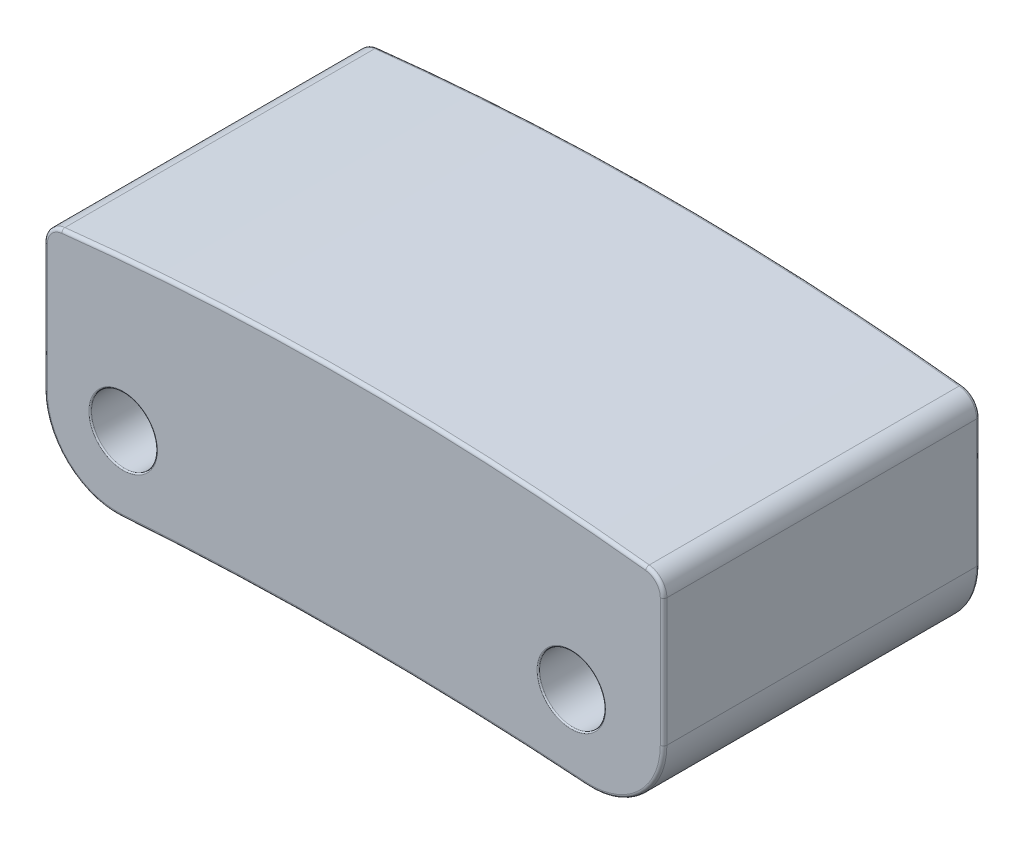
from build123d import *

# Parameters (mm, degrees)
SKETCH1_W               = 9.4
SKETCH1_H               = 3.7
BOSS_EXTRUDE1_DEPTH     = 2.4
CUT_EXTRUDE1_DEPTH      = 4.8
FILLET1_R               = 1.1
FILLET2_R               = 0.3
FILLET3_R               = 0.05
CUT_EXTRUDE2_START      = 1
SKETCH3_R               = 0.5
CUT_EXTRUDE2_DEPTH      = 4.8
FILLET4_R               = 0.02
CUT_EXTRUDE3_REACH      = 17.585
CUT_EXTRUDE3_END_RADIUS = 50.4
CUT_EXTRUDE3_START      = -10
SKETCH4_R               = 0.4
FILLET5_R               = 0.05


with BuildPart() as part:
    # Sketch1 → Boss-Extrude1 (new, symmetric)
    with BuildSketch(Plane.XY):
        Rectangle(SKETCH1_W, SKETCH1_H)
    extrude(amount=BOSS_EXTRUDE1_DEPTH, both=True)

    # Sketch2 → Cut-Extrude1 (cut)
    with BuildSketch(Plane.XY.offset(2.4)):
        with BuildLine():
            Line((-4.7, 1.55), (-7.120690005, 4.011417256))
            Line((-7.120690005, 4.011417256), (5.535860742, 3.886722174))
            Line((5.535860742, 3.886722174), (4.7, 1.55))
            ThreePointArc((4.7, 1.55), (0, 1.827084699), (-4.7, 1.55))
        make_face()
        with BuildLine():
            Line((4.7, -1.85), (0.350623614, -3.782025322))
            Line((0.350623614, -3.782025322), (-4.7, -1.85))
            ThreePointArc((-4.7, -1.85), (0, -1.628609864), (4.7, -1.85))
        make_face()
    extrude(amount=-CUT_EXTRUDE1_DEPTH, mode=Mode.SUBTRACT)

    # Fillet1
    fillet1_edges = [part.edges().sort_by_distance(p)[0] for p in [
        (4.7, -1.85, 0),
        (-4.7, -1.85, 0),
    ]]
    fillet(fillet1_edges, radius=FILLET1_R)

    # Fillet2
    fillet2_edges = [part.edges().sort_by_distance(p)[0] for p in [
        (4.7, 1.55, 0),
        (-4.7, 1.55, 0),
    ]]
    fillet(fillet2_edges, radius=FILLET2_R)

    # Fillet3
    fillet3_edges = [part.edges().sort_by_distance(p)[0] for p in [
        (4.7, 0.3134624, -2.4),
        (4.7, 0.3134624, 2.4),
        (0, -1.628609864, -2.4),
        (-4.349918456, -1.460327621, -2.4),
        (4.349918456, -1.460327621, -2.4),
        (0, -1.628609864, 2.4),
        (-4.349918456, -1.460327621, 2.4),
        (4.349918456, -1.460327621, 2.4),
        (0, 1.827084699, 2.4),
        (-4.7, 0.3134624, 2.4),
        (-4.623578634, 1.482534062, 2.4),
        (4.623578634, 1.482534062, 2.4),
        (0, 1.827084699, -2.4),
        (-4.7, 0.3134624, -2.4),
        (-4.623578634, 1.482534062, -2.4),
        (4.623578634, 1.482534062, -2.4),
    ]]
    fillet(fillet3_edges, radius=FILLET3_R)

    # Sketch3 → Cut-Extrude2 (cut)
    with BuildSketch(Plane.XY.offset(2.4).offset(CUT_EXTRUDE2_START)):
        with Locations((3.3, -0.6)):
            Circle(SKETCH3_R)
        with Locations((-3.5, -0.6)):
            Circle(SKETCH3_R)
    extrude(amount=-CUT_EXTRUDE2_DEPTH, mode=Mode.SUBTRACT)

    # Fillet4
    fillet4_edges = [part.edges().sort_by_distance(p)[0] for p in [
        (2.8, -0.6, 2.4),
        (-4, -0.6, 2.4),
    ]]
    fillet(fillet4_edges, radius=FILLET4_R)

    # Cut-Extrude3: up to this cylinder (the profile starts inside it)
    cut_extrude3_end = Plane(origin=(0, -51.628609864, 0.9), z_dir=(0, 0, 1)) * Cylinder(CUT_EXTRUDE3_END_RADIUS, 136.97, mode=Mode.PRIVATE)
    # Sketch4 → Cut-Extrude3 (cut, up to the surface)
    with BuildSketch(Plane(origin=(0, 0, 0), x_dir=(1, 0, 0), z_dir=(0, 1, 0)).offset(CUT_EXTRUDE3_START), mode=Mode.PRIVATE) as cut_extrude3_sk1:
        with Locations(Location((-0.05, -0.9, 0), (0, 0, 90))):
            Circle(SKETCH4_R)
    cut_extrude3_tool1 = extrude(cut_extrude3_sk1.sketch, amount=CUT_EXTRUDE3_REACH, mode=Mode.PRIVATE) & cut_extrude3_end
    add(cut_extrude3_tool1.solids().sort_by_distance((-0.05, -10, 0.9))[0], mode=Mode.SUBTRACT)

    # Fillet5
    fillet5_edges = [part.edges().sort_by_distance(p)[0] for p in [
        (-0.050002133, -1.628634866, 1.3),
    ]]
    fillet(fillet5_edges, radius=FILLET5_R)


solid = part.part
